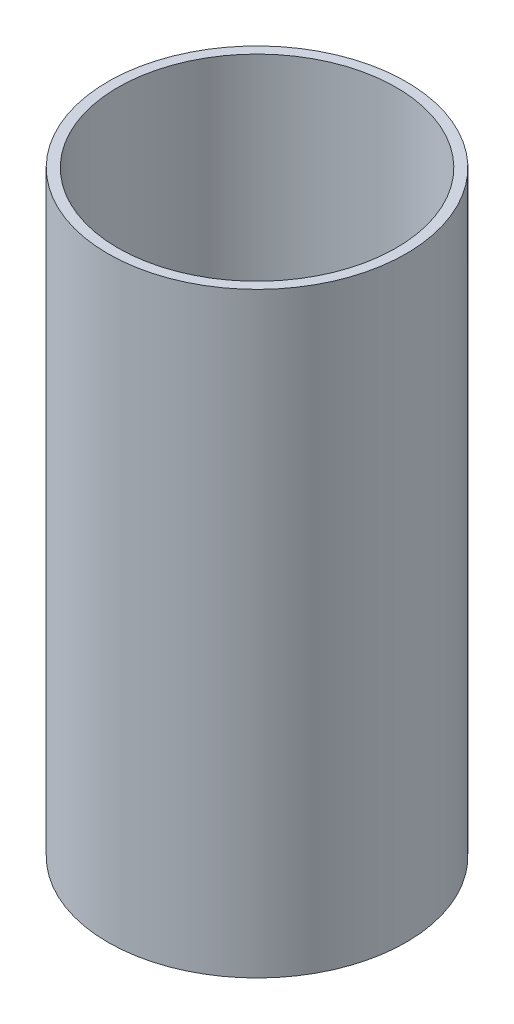
from build123d import *

# Parameters (mm, degrees)
SKETCH_1_R          = 3
EXTRUDE_1_DEPTH     = 12
SKETCH_2_R          = 2.8
CUT_EXTRUDE_1_DEPTH = 12


with BuildPart() as part:
    # 草图1 → 凸台-拉伸1 (new body)
    with BuildSketch(Plane(origin=(0, 0, 0), x_dir=(1, 0, 0), z_dir=(0, 1, 0))):
        Circle(SKETCH_1_R)
    extrude(amount=EXTRUDE_1_DEPTH)

    # 草图2 → 切除-拉伸1 (cut)
    with BuildSketch(Plane(origin=(0, 12, 0), x_dir=(1, 0, 0), z_dir=(0, 1, 0))):
        Circle(SKETCH_2_R)
    extrude(amount=-CUT_EXTRUDE_1_DEPTH, mode=Mode.SUBTRACT)


solid = part.part
